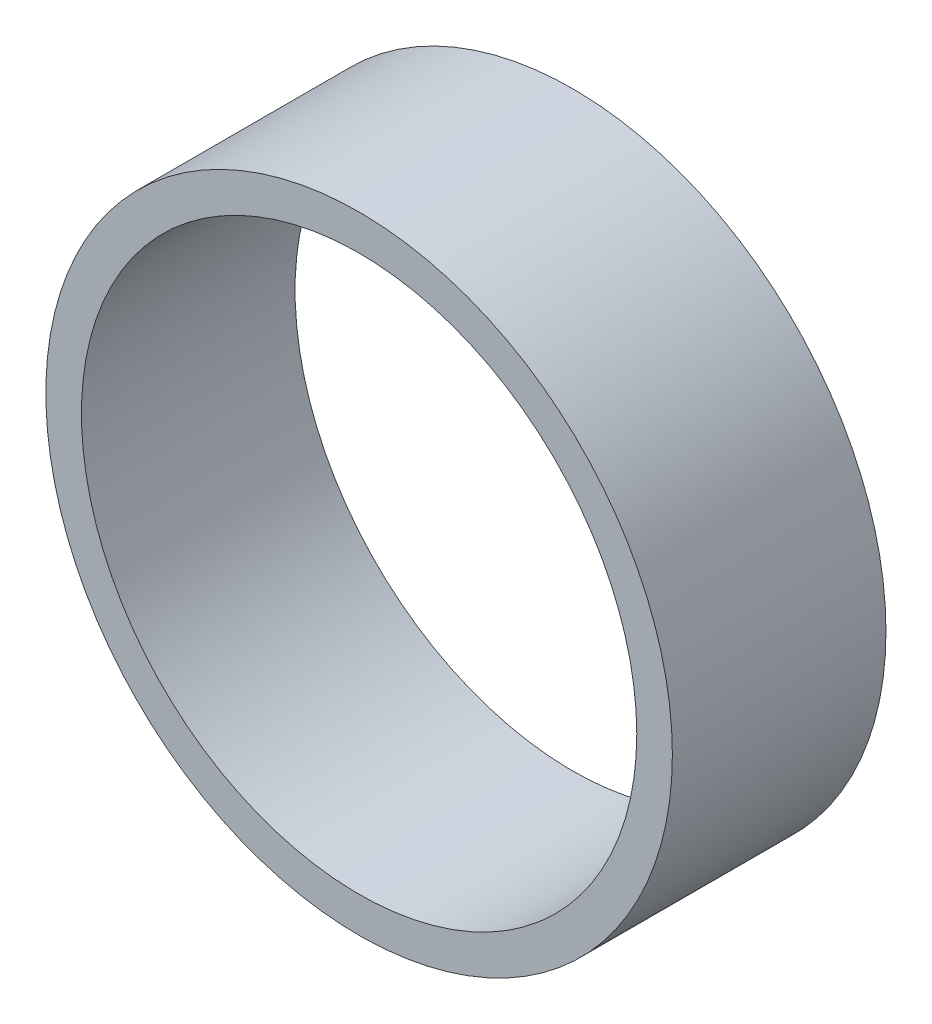
from build123d import *

# Parameters (mm, degrees)
ESQUISSE1_R        = 44
ESQUISSE1_R_2      = 39
BOSS_EXTRU_1_DEPTH = 30


with BuildPart() as part:
    # Esquisse1 → Boss.-Extru.1 (new body)
    with BuildSketch(Plane.XY):
        Circle(ESQUISSE1_R)
        Circle(ESQUISSE1_R_2, mode=Mode.SUBTRACT)
    extrude(amount=BOSS_EXTRU_1_DEPTH)


solid = part.part
